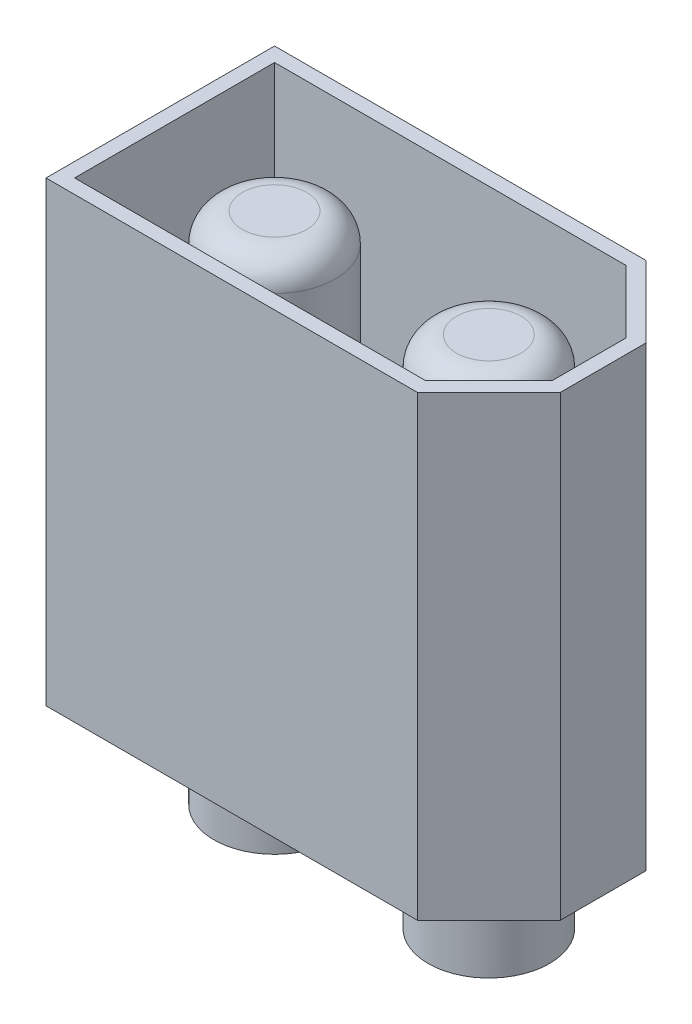
from build123d import *

# Parameters (mm, degrees)
BOSS_EXTRUDE1_DEPTH      = 16
SHELL1_T                 = -0.5
SHELL1_THICKNESS_2_DEPTH = 6.5
SKETCH2_R                = 3
CUT_EXTRUDE1_DEPTH       = 1.5
SKETCH3_R                = 2.125
BOSS_EXTRUDE2_DEPTH      = 4.5
SKETCH4_R                = 2.125
BOSS_EXTRUDE3_DEPTH      = 8
FILLET1_R                = 1


with BuildPart() as part:
    # Sketch1 → Boss-Extrude1 (new body)
    with BuildSketch(Plane(origin=(0, 0, 0), x_dir=(1, 0, 0), z_dir=(0, 1, 0))):
        Polygon((7.75, 1.5), (5.25, 4), (-7.75, 4), (-7.75, -4), (5.25, -4), (7.75, -1.5), align=None)
    extrude(amount=BOSS_EXTRUDE1_DEPTH)

    # Shell1
    shell1_openings = [part.faces().sort_by_distance(p)[0] for p in [
        (-0.367126681, 16, 0),
    ]]
    offset(amount=SHELL1_T, openings=shell1_openings, kind=Kind.INTERSECTION)

    # Shell1 thickness 2 face (on inner face of the shell) → Shell1 thickness 2 (add)
    with BuildSketch(Plane(origin=(-0.328403857, 0.5, 0), x_dir=(0, 0, -1), z_dir=(0, -1, 0))):
        Polygon((-1.292893219, 7.578403857), (1.292893219, 7.578403857), (3.5, 5.371297076), (3.5, -6.921596143), (-3.5, -6.921596143), (-3.5, 5.371297076), align=None)
    extrude(amount=-SHELL1_THICKNESS_2_DEPTH)

    # Sketch2 → Cut-Extrude1 (cut)
    with BuildSketch(Plane.XZ):
        with Locations(Location((-3.75, 0, 0), (0, 0, 270))):
            Circle(SKETCH2_R)
        with Locations(Location((3.75, 0, 0), (0, 0, 90))):
            Circle(SKETCH2_R)
    extrude(amount=-CUT_EXTRUDE1_DEPTH, mode=Mode.SUBTRACT)

    # Sketch3 → Boss-Extrude2 (add)
    with BuildSketch(Plane.XZ.offset(-1.5)):
        with Locations(Location((-3.75, 0, 0), (0, 0, 270))):
            Circle(SKETCH3_R)
        with Locations(Location((3.75, 0, 0), (0, 0, 90))):
            Circle(SKETCH3_R)
    extrude(amount=BOSS_EXTRUDE2_DEPTH)

    # Sketch4 → Boss-Extrude3 (add)
    with BuildSketch(Plane(origin=(0, 7, 0), x_dir=(1, 0, 0), z_dir=(0, 1, 0))):
        with Locations(Location((-3.75, 0, 0), (0, 0, 90))):
            Circle(SKETCH4_R)
        with Locations(Location((3.75, 0, 0), (0, 0, 270))):
            Circle(SKETCH4_R)
    extrude(amount=BOSS_EXTRUDE3_DEPTH)

    # Fillet1
    fillet1_edges = [part.edges().sort_by_distance(p)[0] for p in [
        (-3.75, 15, 2.125),
        (3.75, 15, -2.125),
    ]]
    fillet(fillet1_edges, radius=FILLET1_R)


solid = part.part
